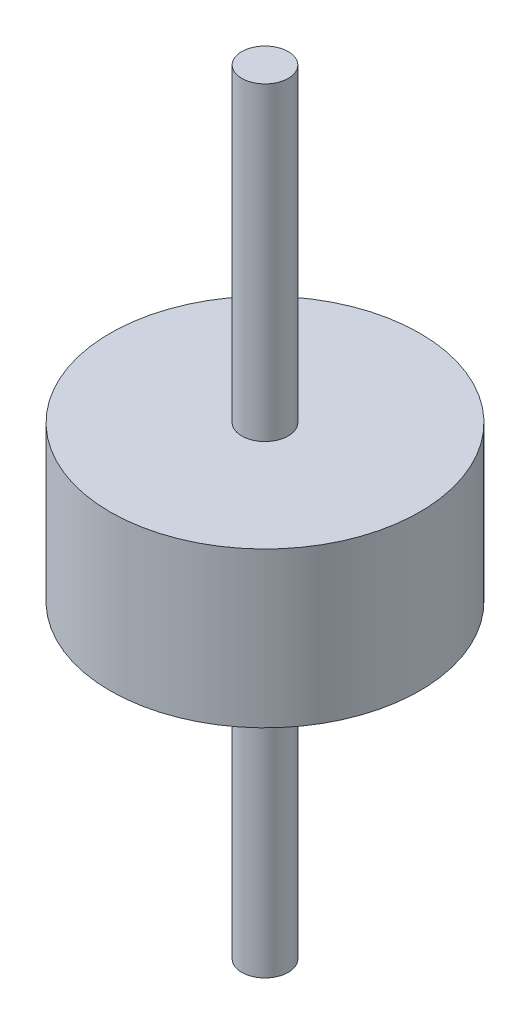
from build123d import *

# Parameters (mm, degrees)
SKETCH1_R           = 5.08
BOSS_EXTRUDE2_DEPTH = 5.08
SKETCH2_R           = 0.762
BOSS_EXTRUDE3_DEPTH = 10.16
SKETCH3_R           = 0.762
BOSS_EXTRUDE4_DEPTH = 10.16


with BuildPart() as part:
    # Sketch1 → Boss-Extrude2 (new body)
    with BuildSketch(Plane(origin=(0, 0, 0), x_dir=(1, 0, 0), z_dir=(0, 1, 0))):
        with Locations((-10.119861789, -11.302088634)):
            Circle(SKETCH1_R)
    extrude(amount=BOSS_EXTRUDE2_DEPTH)

    # Sketch2 → Boss-Extrude3 (add)
    with BuildSketch(Plane(origin=(0, 5.08, 0), x_dir=(1, 0, 0), z_dir=(0, 1, 0))):
        with Locations((-10.119861789, -11.302088634)):
            Circle(SKETCH2_R)
    extrude(amount=BOSS_EXTRUDE3_DEPTH)

    # Sketch3 → Boss-Extrude4 (add)
    with BuildSketch(Plane.XZ):
        with Locations((-10.119861789, 11.302088634)):
            Circle(SKETCH3_R)
    extrude(amount=BOSS_EXTRUDE4_DEPTH)


solid = part.part
